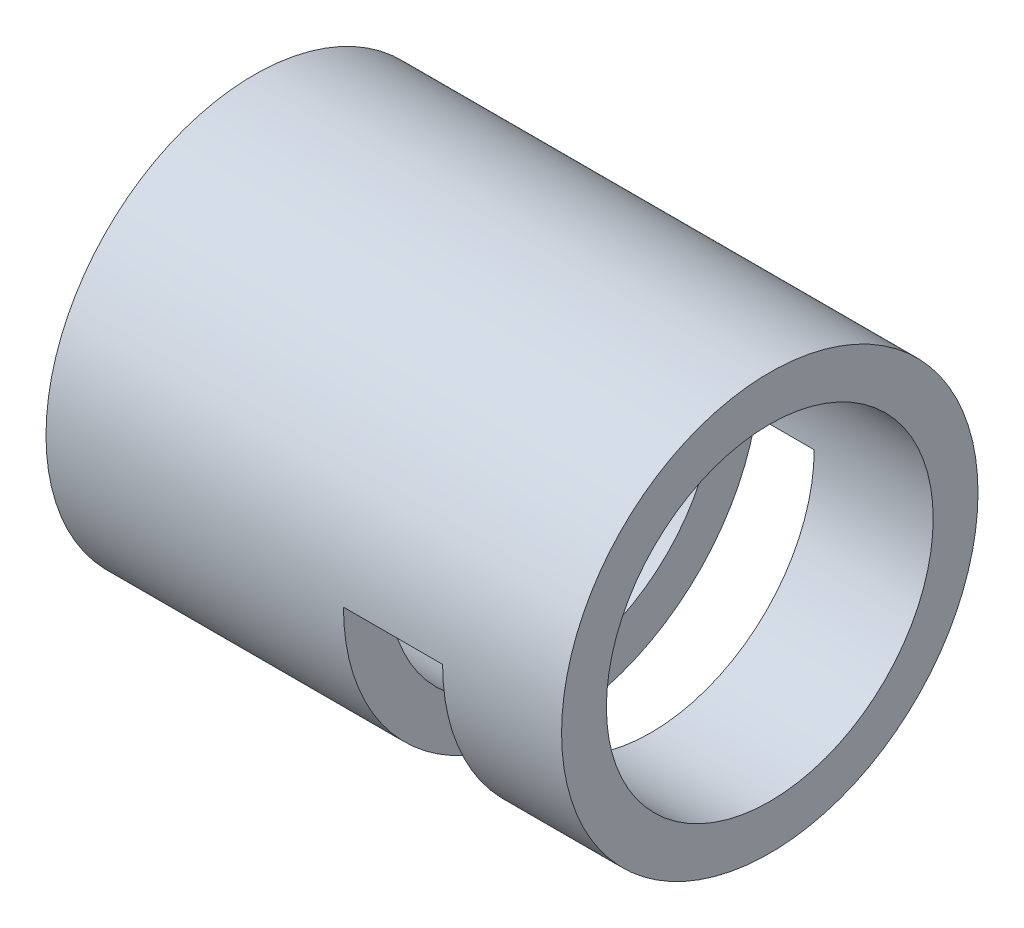
from build123d import *

# Parameters (mm, degrees)
SKETCH1_R               = 13.335
SKETCH1_R_2             = 10.4648
BOSS_EXTRUDE1_DEPTH     = 33.02
SKETCH2_W               = 6.35
SKETCH2_H               = 13.335
CUT_EXTRUDE1_DEPTH      = 14.335
CUT_EXTRUDE1_DEPTH_BACK = 14.335


with BuildPart() as part:
    # Sketch1 → Boss-Extrude1 (new body)
    with BuildSketch(Plane(origin=(0, 0, 0), x_dir=(0, 0, -1), z_dir=(1, 0, 0))):
        Circle(SKETCH1_R)
        Circle(SKETCH1_R_2, mode=Mode.SUBTRACT)
    extrude(amount=BOSS_EXTRUDE1_DEPTH)

    # Sketch2 → Cut-Extrude1 (cut, two sides)
    with BuildSketch(Plane.XY) as cut_extrude1_sk:
        with Locations((22.225, -6.6675)):
            Rectangle(SKETCH2_W, SKETCH2_H)
    extrude(amount=CUT_EXTRUDE1_DEPTH, mode=Mode.SUBTRACT)
    extrude(cut_extrude1_sk.sketch, amount=-CUT_EXTRUDE1_DEPTH_BACK, mode=Mode.SUBTRACT)


solid = part.part
